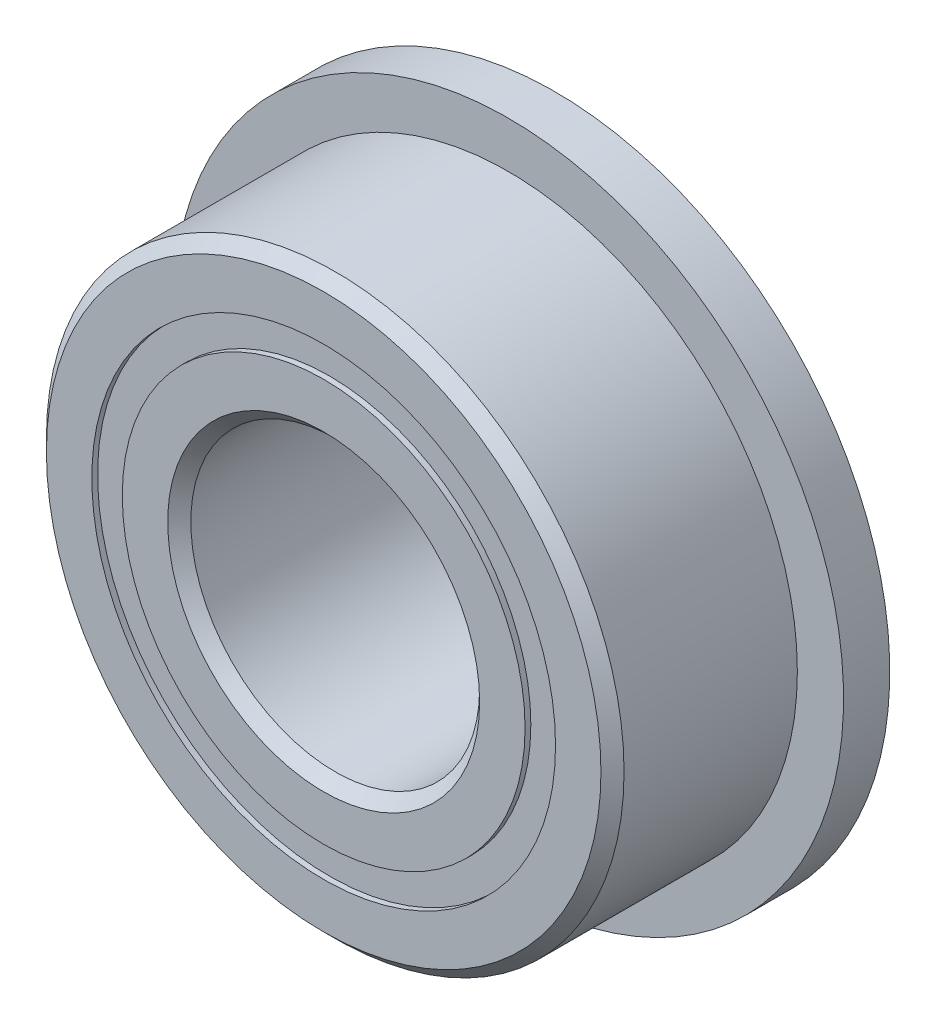
from build123d import *

# Parameters (mm, degrees)
CIRPATTERN1_COUNT = 12
SKETCH5_W         = 0.972810551
SKETCH5_H         = 0.527472528
SKETCH6_W         = 0.8
SKETCH6_H         = 1.786263736


with BuildPart() as part:
    # Sketch1 → Revolve1 (revolve)
    with BuildSketch(Plane(origin=(0, 0, 0), x_dir=(0, 0, -1), z_dir=(1, 0, 0))):
        with BuildLine():
            Line((1.8, 5), (-1.8, 5))
            Line((-1.8, 5), (-2, 4.8))
            Line((-2, 4.8), (-2, 4.013736264))
            Line((-2, 4.013736264), (-0.888888889, 4.013736264))
            ThreePointArc((-0.888888889, 4.013736264), (0, 4.677189449), (0.888888889, 4.013736264))
            Line((0.888888889, 4.013736264), (2, 4.013736264))
            Line((2, 4.013736264), (2, 4.8))
            Line((2, 4.8), (1.8, 5))
        make_face()
    revolve(axis=Axis((0, 0, 2), (0, 0, -1)))

    # Sketch6 → Revolve6 (revolve)
    with BuildSketch(Plane(origin=(0, 0, 0), x_dir=(0, 0, -1), z_dir=(1, 0, 0))):
        with Locations((1.6, 4.906868132)):
            Rectangle(SKETCH6_W, SKETCH6_H)
    revolve(axis=Axis((0, 0, -2), (0, 0, 1)))


with BuildPart() as body_2:
    # Sketch3 → Revolve3 (revolve)
    with BuildSketch(Plane(origin=(0, 0, 0), x_dir=(0, 0, -1), z_dir=(1, 0, 0))):
        with BuildLine():
            Line((-2, 3.486263736), (-0.888888889, 3.486263736))
            ThreePointArc((-0.888888889, 3.486263736), (0, 2.822810551), (0.888888889, 3.486263736))
            Line((0.888888889, 3.486263736), (2, 3.486263736))
            Line((2, 3.486263736), (2, 2.7))
            Line((2, 2.7), (1.8, 2.5))
            Line((1.8, 2.5), (-1.8, 2.5))
            Line((-1.8, 2.5), (-2, 2.7))
            Line((-2, 2.7), (-2, 3.486263736))
        make_face()
    revolve(axis=Axis((0, 0, 2), (0, 0, -1)))


with BuildPart() as body_3:
    # Sketch4 → Revolve4 (revolve)
    with BuildSketch(Plane(origin=(0, 0, 0), x_dir=(0, 0, -1), z_dir=(1, 0, 0))):
        with BuildLine():
            Line((-0.927189449, 3.75), (0.927189449, 3.75))
            ThreePointArc((0.927189449, 3.75), (0, 4.677189449), (-0.927189449, 3.75))
        make_face()
    revolve(axis=Axis((0, 3.75, 0.927189449), (0, 0, -1)))


with BuildPart() as cirpattern1_1:
    # CirPattern1: pattern copy
    add(body_3.part.rotate(Axis((0, 0, -2), (0, 0, 1)), 1 * 360 / CIRPATTERN1_COUNT))


with BuildPart() as cirpattern1_2:
    # CirPattern1: pattern copy
    add(body_3.part.rotate(Axis((0, 0, -2), (0, 0, 1)), 2 * 360 / CIRPATTERN1_COUNT))


with BuildPart() as cirpattern1_3:
    # CirPattern1: pattern copy
    add(body_3.part.rotate(Axis((0, 0, -2), (0, 0, 1)), 3 * 360 / CIRPATTERN1_COUNT))


with BuildPart() as cirpattern1_4:
    # CirPattern1: pattern copy
    add(body_3.part.rotate(Axis((0, 0, -2), (0, 0, 1)), 4 * 360 / CIRPATTERN1_COUNT))


with BuildPart() as cirpattern1_5:
    # CirPattern1: pattern copy
    add(body_3.part.rotate(Axis((0, 0, -2), (0, 0, 1)), 5 * 360 / CIRPATTERN1_COUNT))


with BuildPart() as cirpattern1_6:
    # CirPattern1: pattern copy
    add(body_3.part.rotate(Axis((0, 0, -2), (0, 0, 1)), 6 * 360 / CIRPATTERN1_COUNT))


with BuildPart() as cirpattern1_7:
    # CirPattern1: pattern copy
    add(body_3.part.rotate(Axis((0, 0, -2), (0, 0, 1)), 7 * 360 / CIRPATTERN1_COUNT))


with BuildPart() as cirpattern1_8:
    # CirPattern1: pattern copy
    add(body_3.part.rotate(Axis((0, 0, -2), (0, 0, 1)), 8 * 360 / CIRPATTERN1_COUNT))


with BuildPart() as cirpattern1_9:
    # CirPattern1: pattern copy
    add(body_3.part.rotate(Axis((0, 0, -2), (0, 0, 1)), 9 * 360 / CIRPATTERN1_COUNT))


with BuildPart() as cirpattern1_10:
    # CirPattern1: pattern copy
    add(body_3.part.rotate(Axis((0, 0, -2), (0, 0, 1)), 10 * 360 / CIRPATTERN1_COUNT))


with BuildPart() as cirpattern1_11:
    # CirPattern1: pattern copy
    add(body_3.part.rotate(Axis((0, 0, -2), (0, 0, 1)), 11 * 360 / CIRPATTERN1_COUNT))


with BuildPart() as body_15:
    # Sketch5 → Revolve5 (revolve)
    with BuildSketch(Plane(origin=(0, 0, 0), x_dir=(0, 0, -1), z_dir=(1, 0, 0))):
        with Locations((-1.413594725, 3.75)):
            Rectangle(SKETCH5_W, SKETCH5_H)
        with Locations((1.413594725, 3.75)):
            Rectangle(SKETCH5_W, SKETCH5_H)
    revolve(axis=Axis((0, 0, 2), (0, 0, -1)))


solid = Compound([part.part, body_2.part, body_3.part, cirpattern1_1.part, cirpattern1_2.part, cirpattern1_3.part, cirpattern1_4.part, cirpattern1_5.part, cirpattern1_6.part, cirpattern1_7.part, cirpattern1_8.part, cirpattern1_9.part, cirpattern1_10.part, cirpattern1_11.part, body_15.part])
